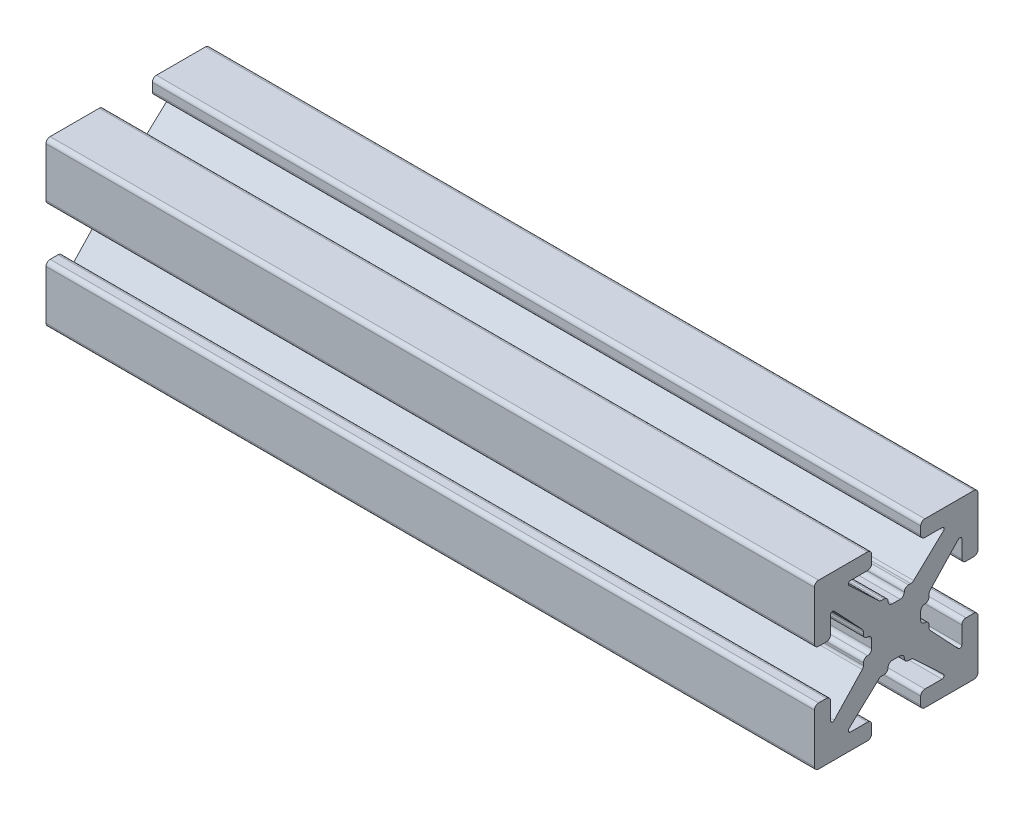
from build123d import *

# Parameters (mm, degrees)
BOSS_EXTRU_1_DEPTH = 47


with BuildPart() as part:
    # Sketch1 → Boss.-Extru.1 (new body)
    with BuildSketch(Plane(origin=(0, 0, 0), x_dir=(0, 0, -1), z_dir=(1, 0, 0))):
        with BuildLine():
            Line((-0.2413, 1.4986), (0.2413, 1.4986))
            ThreePointArc((0.2413, 1.4986), (0.420905122, 1.572994878), (0.4953, 1.7526))
            ThreePointArc((0.4953, 1.7526), (0.569694878, 1.932205122), (0.7493, 2.0066))
            Line((0.7493, 2.0066), (0.889923986, 2.0066))
            ThreePointArc((0.889923986, 2.0066), (0.983516259, 2.024471886), (1.063937899, 2.075572548))
            Line((1.063937899, 2.075572548), (2.890793, 3.793686274))
            ThreePointArc((2.890793, 3.793686274), (2.921850101, 3.932996137), (2.803786044, 4.0132))
            Line((2.803786044, 4.0132), (1.7526, 4.0132))
            ThreePointArc((1.7526, 4.0132), (1.572994878, 4.087594878), (1.4986, 4.2672))
            Line((1.4986, 4.2672), (1.4986, 4.7498))
            ThreePointArc((1.4986, 4.7498), (1.572994878, 4.929405122), (1.7526, 5.0038))
            Line((1.7526, 5.0038), (4.7498, 5.0038))
            ThreePointArc((4.7498, 5.0038), (4.929405122, 4.929405122), (5.0038, 4.7498))
            Line((5.0038, 4.7498), (5.0038, 1.7526))
            ThreePointArc((5.0038, 1.7526), (4.929405122, 1.572994878), (4.7498, 1.4986))
            Line((4.7498, 1.4986), (4.2672, 1.4986))
            ThreePointArc((4.2672, 1.4986), (4.087594878, 1.572994878), (4.0132, 1.7526))
            Line((4.0132, 1.7526), (4.0132, 2.803786044))
            ThreePointArc((4.0132, 2.803786044), (3.932996137, 2.921850101), (3.793686274, 2.890793))
            Line((3.793686274, 2.890793), (2.075572548, 1.063937899))
            ThreePointArc((2.075572548, 1.063937899), (2.024471886, 0.983516259), (2.0066, 0.889923986))
            Line((2.0066, 0.889923986), (2.0066, 0.7493))
            ThreePointArc((2.0066, 0.7493), (1.932205122, 0.569694878), (1.7526, 0.4953))
            ThreePointArc((1.7526, 0.4953), (1.572994878, 0.420905122), (1.4986, 0.2413))
            Line((1.4986, 0.2413), (1.4986, -0.2413))
            ThreePointArc((1.4986, -0.2413), (1.572994878, -0.420905122), (1.7526, -0.4953))
            ThreePointArc((1.7526, -0.4953), (1.932205122, -0.569694878), (2.0066, -0.7493))
            Line((2.0066, -0.7493), (2.0066, -0.889923986))
            ThreePointArc((2.0066, -0.889923986), (2.024471886, -0.983516259), (2.075572548, -1.063937899))
            Line((2.075572548, -1.063937899), (3.793686274, -2.890793))
            ThreePointArc((3.793686274, -2.890793), (3.932996137, -2.921850101), (4.0132, -2.803786044))
            Line((4.0132, -2.803786044), (4.0132, -1.7526))
            ThreePointArc((4.0132, -1.7526), (4.087594878, -1.572994878), (4.2672, -1.4986))
            Line((4.2672, -1.4986), (4.7498, -1.4986))
            ThreePointArc((4.7498, -1.4986), (4.929405122, -1.572994878), (5.0038, -1.7526))
            Line((5.0038, -1.7526), (5.0038, -4.7498))
            ThreePointArc((5.0038, -4.7498), (4.929405122, -4.929405122), (4.7498, -5.0038))
            Line((4.7498, -5.0038), (1.7526, -5.0038))
            ThreePointArc((1.7526, -5.0038), (1.572994878, -4.929405122), (1.4986, -4.7498))
            Line((1.4986, -4.7498), (1.4986, -4.2672))
            ThreePointArc((1.4986, -4.2672), (1.572994878, -4.087594878), (1.7526, -4.0132))
            Line((1.7526, -4.0132), (2.803786044, -4.0132))
            ThreePointArc((2.803786044, -4.0132), (2.921850101, -3.932996137), (2.890793, -3.793686274))
            Line((2.890793, -3.793686274), (1.063937899, -2.075572548))
            ThreePointArc((1.063937899, -2.075572548), (0.983516259, -2.024471886), (0.889923986, -2.0066))
            Line((0.889923986, -2.0066), (0.7493, -2.0066))
            ThreePointArc((0.7493, -2.0066), (0.569694878, -1.932205122), (0.4953, -1.7526))
            ThreePointArc((0.4953, -1.7526), (0.420905122, -1.572994878), (0.2413, -1.4986))
            Line((0.2413, -1.4986), (-0.2413, -1.4986))
            ThreePointArc((-0.2413, -1.4986), (-0.420905122, -1.572994878), (-0.4953, -1.7526))
            ThreePointArc((-0.4953, -1.7526), (-0.569694878, -1.932205122), (-0.7493, -2.0066))
            Line((-0.7493, -2.0066), (-0.889923986, -2.0066))
            ThreePointArc((-0.889923986, -2.0066), (-0.983516259, -2.024471886), (-1.063937899, -2.075572548))
            Line((-1.063937899, -2.075572548), (-2.890793, -3.793686274))
            ThreePointArc((-2.890793, -3.793686274), (-2.921850101, -3.932996137), (-2.803786044, -4.0132))
            Line((-2.803786044, -4.0132), (-1.7526, -4.0132))
            ThreePointArc((-1.7526, -4.0132), (-1.572994878, -4.087594878), (-1.4986, -4.2672))
            Line((-1.4986, -4.2672), (-1.4986, -4.7498))
            ThreePointArc((-1.4986, -4.7498), (-1.572994878, -4.929405122), (-1.7526, -5.0038))
            Line((-1.7526, -5.0038), (-4.7498, -5.0038))
            ThreePointArc((-4.7498, -5.0038), (-4.929405122, -4.929405122), (-5.0038, -4.7498))
            Line((-5.0038, -4.7498), (-5.0038, -1.7526))
            ThreePointArc((-5.0038, -1.7526), (-4.929405122, -1.572994878), (-4.7498, -1.4986))
            Line((-4.7498, -1.4986), (-4.2672, -1.4986))
            ThreePointArc((-4.2672, -1.4986), (-4.087594878, -1.572994878), (-4.0132, -1.7526))
            Line((-4.0132, -1.7526), (-4.0132, -2.803786044))
            ThreePointArc((-4.0132, -2.803786044), (-3.932996137, -2.921850101), (-3.793686274, -2.890793))
            Line((-3.793686274, -2.890793), (-2.075572548, -1.063937899))
            ThreePointArc((-2.075572548, -1.063937899), (-2.024471886, -0.983516259), (-2.0066, -0.889923986))
            Line((-2.0066, -0.889923986), (-2.0066, -0.7493))
            ThreePointArc((-2.0066, -0.7493), (-1.932205122, -0.569694878), (-1.7526, -0.4953))
            ThreePointArc((-1.7526, -0.4953), (-1.572994878, -0.420905122), (-1.4986, -0.2413))
            Line((-1.4986, -0.2413), (-1.4986, 0.2413))
            ThreePointArc((-1.4986, 0.2413), (-1.572994878, 0.420905122), (-1.7526, 0.4953))
            ThreePointArc((-1.7526, 0.4953), (-1.932205122, 0.569694878), (-2.0066, 0.7493))
            Line((-2.0066, 0.7493), (-2.0066, 0.889923986))
            ThreePointArc((-2.0066, 0.889923986), (-2.024471886, 0.983516259), (-2.075572548, 1.063937899))
            Line((-2.075572548, 1.063937899), (-3.793686274, 2.890793))
            ThreePointArc((-3.793686274, 2.890793), (-3.932996137, 2.921850101), (-4.0132, 2.803786044))
            Line((-4.0132, 2.803786044), (-4.0132, 1.7526))
            ThreePointArc((-4.0132, 1.7526), (-4.087594878, 1.572994878), (-4.2672, 1.4986))
            Line((-4.2672, 1.4986), (-4.7498, 1.4986))
            ThreePointArc((-4.7498, 1.4986), (-4.929405122, 1.572994878), (-5.0038, 1.7526))
            Line((-5.0038, 1.7526), (-5.0038, 4.7498))
            ThreePointArc((-5.0038, 4.7498), (-4.929405122, 4.929405122), (-4.7498, 5.0038))
            Line((-4.7498, 5.0038), (-1.7526, 5.0038))
            ThreePointArc((-1.7526, 5.0038), (-1.572994878, 4.929405122), (-1.4986, 4.7498))
            Line((-1.4986, 4.7498), (-1.4986, 4.2672))
            ThreePointArc((-1.4986, 4.2672), (-1.572994878, 4.087594878), (-1.7526, 4.0132))
            Line((-1.7526, 4.0132), (-2.803786044, 4.0132))
            ThreePointArc((-2.803786044, 4.0132), (-2.921850101, 3.932996137), (-2.890793, 3.793686274))
            Line((-2.890793, 3.793686274), (-1.063937899, 2.075572548))
            ThreePointArc((-1.063937899, 2.075572548), (-0.983516259, 2.024471886), (-0.889923986, 2.0066))
            Line((-0.889923986, 2.0066), (-0.7493, 2.0066))
            ThreePointArc((-0.7493, 2.0066), (-0.569694878, 1.932205122), (-0.4953, 1.7526))
            ThreePointArc((-0.4953, 1.7526), (-0.420905122, 1.572994878), (-0.2413, 1.4986))
        make_face()
    extrude(amount=BOSS_EXTRU_1_DEPTH)


solid = part.part
